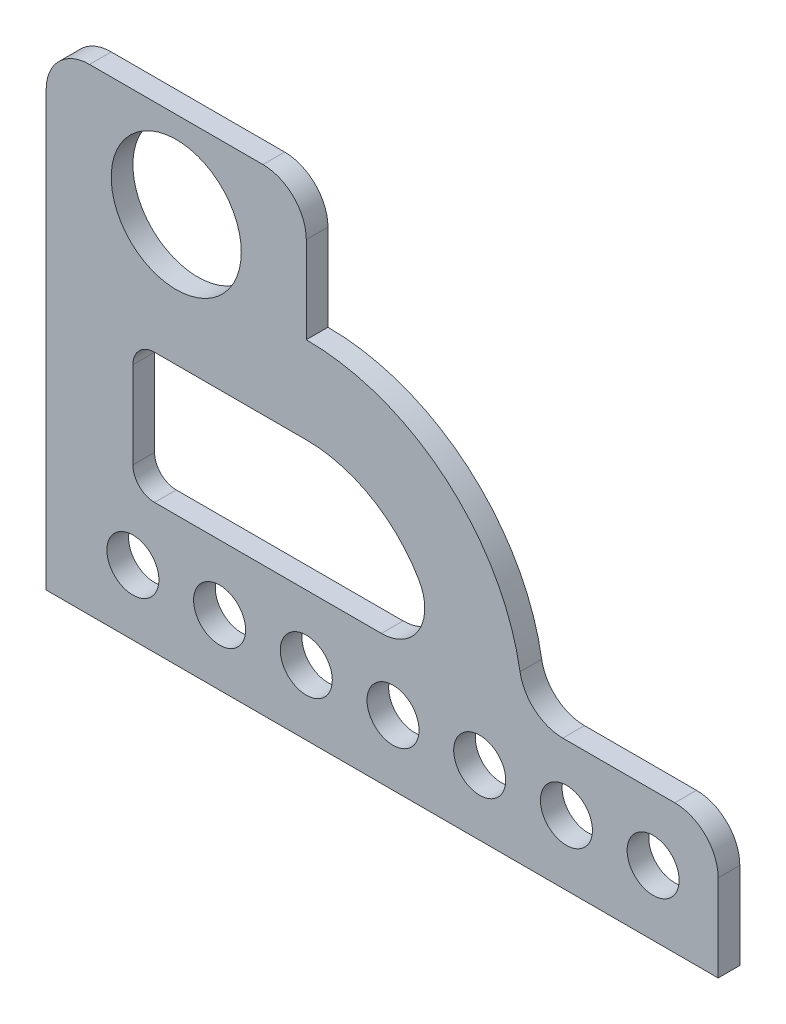
from build123d import *

# Parameters (mm, degrees)
SKETCH2_R           = 15
SKETCH2_R_2         = 6
BOSS_EXTRUDE1_DEPTH = 5


with BuildPart() as part:
    # Sketch2 → Boss-Extrude1 (new body)
    with BuildSketch(Plane.XY):
        with BuildLine():
            Line((0, 0), (-155, 0))
            Line((-155, 0), (-155, 100))
            ThreePointArc((-155, 100), (-152.071067812, 107.071067812), (-145, 110))
            Line((-145, 110), (-105, 110))
            ThreePointArc((-105, 110), (-97.928932188, 107.071067812), (-95, 100))
            Line((-95, 100), (-95, 80))
            ThreePointArc((-95, 80), (-62.725138782, 68.188130791), (-45.699335141, 38.333333333))
            ThreePointArc((-45.699335141, 38.333333333), (-42.294174413, 32.362373842), (-35.839202169, 30))
            Line((-35.839202169, 30), (-10, 30))
            ThreePointArc((-10, 30), (-2.928932188, 27.071067812), (0, 20))
            Line((0, 20), (0, 0))
        make_face()
        with Locations((-125, 90)):
            Circle(SKETCH2_R, mode=Mode.SUBTRACT)
        with Locations((-135, 15)):
            Circle(SKETCH2_R_2, mode=Mode.SUBTRACT)
        with Locations((-115, 15)):
            Circle(SKETCH2_R_2, mode=Mode.SUBTRACT)
        with Locations((-95, 15)):
            Circle(SKETCH2_R_2, mode=Mode.SUBTRACT)
        with Locations((-75, 15)):
            Circle(SKETCH2_R_2, mode=Mode.SUBTRACT)
        with Locations((-55, 15)):
            Circle(SKETCH2_R_2, mode=Mode.SUBTRACT)
        with Locations((-35, 15)):
            Circle(SKETCH2_R_2, mode=Mode.SUBTRACT)
        with Locations((-15, 15)):
            Circle(SKETCH2_R_2, mode=Mode.SUBTRACT)
        with BuildLine():
            Line((-95, 60), (-130, 60))
            ThreePointArc((-130, 60), (-133.535533906, 58.535533906), (-135, 55))
            Line((-135, 55), (-135, 35))
            ThreePointArc((-135, 35), (-133.535533906, 31.464466094), (-130, 30))
            Line((-130, 30), (-95, 30))
            Line((-95, 30), (-77.679491924, 30))
            ThreePointArc((-77.679491924, 30), (-69.019237886, 35), (-69.019237886, 45))
            ThreePointArc((-69.019237886, 45), (-80, 55.980762114), (-95, 60))
        make_face(mode=Mode.SUBTRACT)
    extrude(amount=BOSS_EXTRUDE1_DEPTH)


solid = part.part
